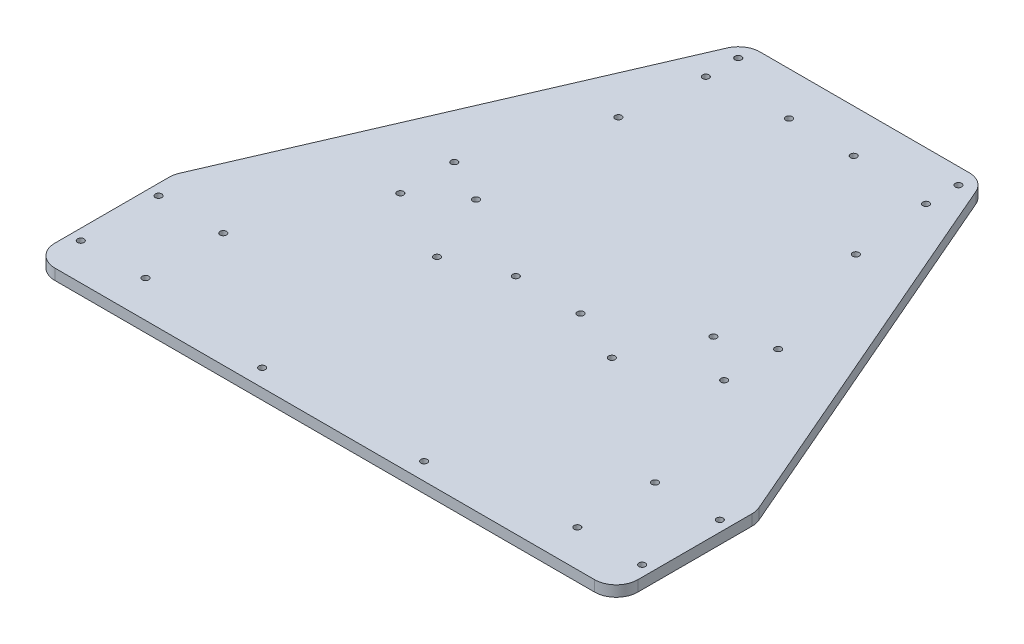
from build123d import *

# Parameters (mm, degrees)
EXTRUDE_837_DEPTH      = 5
SKETCH_2_R             = 1.5
CUT_EXTRUDE_1413_DEPTH = 6
FILLET_1486_R          = 10
SKETCH_9_R             = 1.5
CUT_EXTRUDE_2145_DEPTH = 5
SKETCH_35_R            = 1.5
CUT_EXTRUDE_2803_DEPTH = 5
SKETCH_38_R            = 1.5
CUT_EXTRUDE_1_DEPTH    = 5
SKETCH_39_R            = 1.5
CUT_EXTRUDE_2_DEPTH    = 5
SKETCH_40_R            = 1.5
CUT_EXTRUDE_4396_DEPTH = 5
SKETCH_41_R            = 1.5
CUT_EXTRUDE_4966_DEPTH = 5
SKETCH_43_R            = 1.5
CUT_EXTRUDE_5573_DEPTH = 5
SKETCH_44_R            = 1.5
CPU_DEPTH              = 5


with BuildPart() as part:
    # ｽｹｯﾁ1 → Extrude 837 (new body)
    with BuildSketch(Plane(origin=(0, 0, 0), x_dir=(1, 0, 0), z_dir=(0, 1, 0))):
        Polygon((135, -60), (55, 125), (-55, 125), (-135, -60), (-135, -125), (135, -125), align=None)
    extrude(amount=EXTRUDE_837_DEPTH)

    # ｽｹｯﾁ2 → Cut-Extrude 1413 (cut, through all)
    with BuildSketch(Plane.XZ):
        with Locations(Location((-130, 72, 0), (0, 0, 270))):  # turned: the seam where the file's is
            Circle(SKETCH_2_R)
        with Locations(Location((-130, 108, 0), (0, 0, 270))):  # turned: the seam where the file's is
            Circle(SKETCH_2_R)
        with Locations(Location((130, 72, 0), (0, 0, 270))):  # turned: the seam where the file's is
            Circle(SKETCH_2_R)
        with Locations(Location((130, 108, 0), (0, 0, 270))):  # turned: the seam where the file's is
            Circle(SKETCH_2_R)
    extrude(amount=-CUT_EXTRUDE_1413_DEPTH, mode=Mode.SUBTRACT)

    # Fillet 1486
    fillet_1486_edges = [part.edges().sort_by_distance(p)[0] for p in [
        (55, 2.5, -125),
        (135, 2.5, 60),
        (135, 2.5, 125),
        (-135, 2.5, 125),
        (-135, 2.5, 60),
        (-55, 2.5, -125),
    ]]
    fillet(fillet_1486_edges, radius=FILLET_1486_R)

    # ｽｹｯﾁ9 → Cut-Extrude 2145 (cut)
    with BuildSketch(Plane.XZ):
        with Locations(Location((15, -105, 0), (0, 0, 270))):  # turned: the seam where the file's is
            Circle(SKETCH_9_R)
        with Locations(Location((-15, -105, 0), (0, 0, 270))):  # turned: the seam where the file's is
            Circle(SKETCH_9_R)
    extrude(amount=-CUT_EXTRUDE_2145_DEPTH, mode=Mode.SUBTRACT)

    # ｽｹｯﾁ35 → Cut-Extrude 2803 (cut)
    with BuildSketch(Plane.XZ):
        with Locations(Location((-15, 21.5, 0), (0, 0, 270))):  # turned: the seam where the file's is
            Circle(SKETCH_35_R)
        with Locations(Location((15, 21.5, 0), (0, 0, 270))):  # turned: the seam where the file's is
            Circle(SKETCH_35_R)
    extrude(amount=-CUT_EXTRUDE_2803_DEPTH, mode=Mode.SUBTRACT)

    # ｽｹｯﾁ38 → 内側モータマウンタ穴1 (cut)
    with BuildSketch(Plane.XZ):
        with Locations(Location((-100, 72, 0), (0, 0, 270))):  # turned: the seam where the file's is
            Circle(SKETCH_38_R)
        with Locations(Location((-100, 108, 0), (0, 0, 270))):  # turned: the seam where the file's is
            Circle(SKETCH_38_R)
    extrude(amount=-CUT_EXTRUDE_1_DEPTH, mode=Mode.SUBTRACT)

    # ｽｹｯﾁ39 → 内側モータマウンタ穴2 (cut)
    with BuildSketch(Plane(origin=(0, 0, 0), x_dir=(-1, 0, 0), z_dir=(0, -1, 0))):
        with Locations(Location((-100, -72, 0), (0, 0, 90))):  # turned: the seam where the file's is
            Circle(SKETCH_39_R)
        with Locations(Location((-100, -108, 0), (0, 0, 90))):  # turned: the seam where the file's is
            Circle(SKETCH_39_R)
    extrude(amount=-CUT_EXTRUDE_2_DEPTH, mode=Mode.SUBTRACT)

    # ｽｹｯﾁ40 → Cut-Extrude 4396 (cut)
    with BuildSketch(Plane.XZ):
        with Locations(Location((51, -117.5, 0), (0, 0, 270))):  # turned: the seam where the file's is
            Circle(SKETCH_40_R)
        with Locations(Location((-51, -117.5, 0), (0, 0, 270))):  # turned: the seam where the file's is
            Circle(SKETCH_40_R)
        with Locations(Location((51, -102.5, 0), (0, 0, 270))):  # turned: the seam where the file's is
            Circle(SKETCH_40_R)
        with Locations(Location((-51, -102.5, 0), (0, 0, 270))):  # turned: the seam where the file's is
            Circle(SKETCH_40_R)
    extrude(amount=-CUT_EXTRUDE_4396_DEPTH, mode=Mode.SUBTRACT)

    # ｽｹｯﾁ41 → Cut-Extrude 4966 (cut)
    with BuildSketch(Plane.XZ):
        with Locations(Location((75, 15, 0), (0, 0, 270))):  # turned: the seam where the file's is
            Circle(SKETCH_41_R)
        with Locations(Location((75, -10, 0), (0, 0, 270))):  # turned: the seam where the file's is
            Circle(SKETCH_41_R)
        with Locations(Location((-75, 15, 0), (0, 0, 270))):  # turned: the seam where the file's is
            Circle(SKETCH_41_R)
        with Locations(Location((-75, -10, 0), (0, 0, 270))):  # turned: the seam where the file's is
            Circle(SKETCH_41_R)
    extrude(amount=-CUT_EXTRUDE_4966_DEPTH, mode=Mode.SUBTRACT)

    # ｽｹｯﾁ43 → Cut-Extrude 5573 (cut)
    with BuildSketch(Plane.XZ):
        with Locations(Location((-55, 0, 0), (0, 0, 270))):  # turned: the seam where the file's is
            Circle(SKETCH_43_R)
        with Locations(Location((-55, -66, 0), (0, 0, 270))):  # turned: the seam where the file's is
            Circle(SKETCH_43_R)
        with Locations(Location((55, 0, 0), (0, 0, 270))):  # turned: the seam where the file's is
            Circle(SKETCH_43_R)
        with Locations(Location((55, -66, 0), (0, 0, 270))):  # turned: the seam where the file's is
            Circle(SKETCH_43_R)
    extrude(amount=-CUT_EXTRUDE_5573_DEPTH, mode=Mode.SUBTRACT)

    # ｽｹｯﾁ44 → CPUタワー穴 (cut)
    with BuildSketch(Plane.XZ):
        with Locations(Location((-41, 32, 0), (0, 0, 270))):  # turned: the seam where the file's is
            Circle(SKETCH_44_R)
        with Locations(Location((40, 32, 0), (0, 0, 270))):  # turned: the seam where the file's is
            Circle(SKETCH_44_R)
        with Locations(Location((38, 117, 0), (0, 0, 270))):  # turned: the seam where the file's is
            Circle(SKETCH_44_R)
        with Locations(Location((-37, 117, 0), (0, 0, 270))):  # turned: the seam where the file's is
            Circle(SKETCH_44_R)
    extrude(amount=-CPU_DEPTH, mode=Mode.SUBTRACT)


solid = part.part
